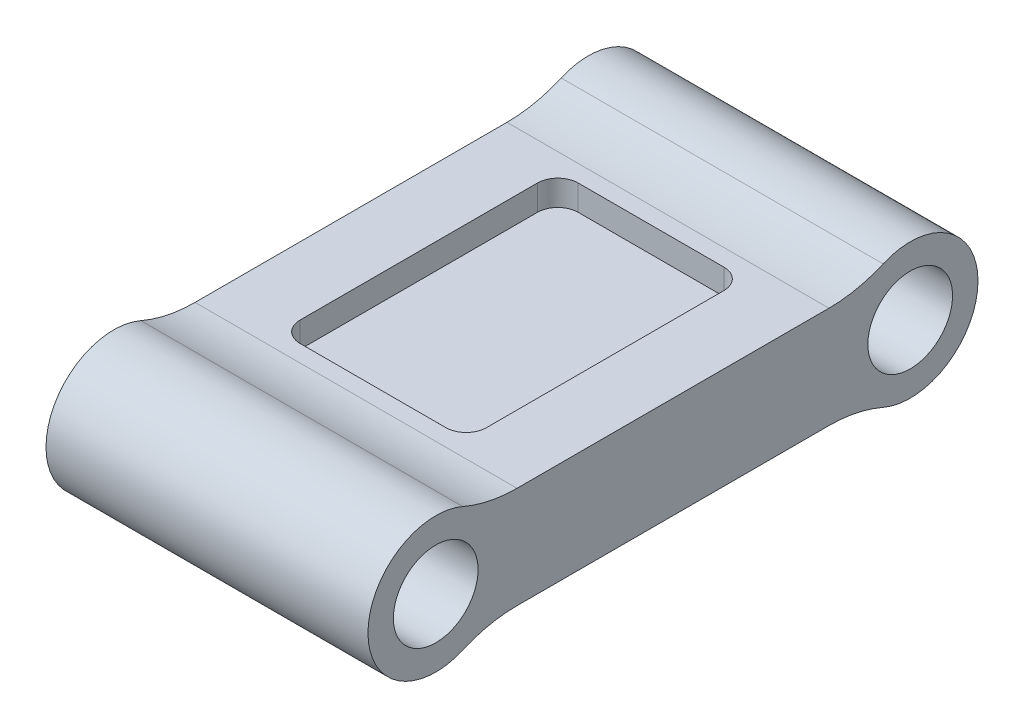
from build123d import *

# Parameters (mm, degrees)
SKETCH1_R               = 15.875
BOSS_EXTRUDE1_DEPTH     = 127
FILLET1_R               = 50.8
SKETCH2_W               = 25.4
SKETCH2_H               = 241.689615924
CUT_EXTRUDE1_DEPTH      = 7.35
CUT_EXTRUDE1_DEPTH_BACK = 45.45
SKETCH3_W               = 69.85
SKETCH3_H               = 104.192939654
CUT_EXTRUDE2_DEPTH      = 9.525
FILLET2_R               = 7.62
FILLET2_OF_MIRROR1_R    = 7.62


with BuildPart() as part:
    # Sketch1 → Boss-Extrude1 (new body)
    with BuildSketch(Plane(origin=(0, 0, 0), x_dir=(0, 0, -1), z_dir=(1, 0, 0))):
        with BuildLine():
            ThreePointArc((16.800520825, 19.05), (-25.4, 0), (16.800520825, -19.05))
            Line((16.800520825, -19.05), (160.999479175, -19.05))
            ThreePointArc((160.999479175, -19.05), (203.2, 0), (160.999479175, 19.05))
            Line((160.999479175, 19.05), (16.800520825, 19.05))
        make_face()
        Circle(SKETCH1_R, mode=Mode.SUBTRACT)
        with Locations((177.8, 0)):
            Circle(SKETCH1_R, mode=Mode.SUBTRACT)
    extrude(amount=BOSS_EXTRUDE1_DEPTH)

    # Fillet1
    fillet1_edges = [part.edges().sort_by_distance(p)[0] for p in [
        (63.5, -19.05, -16.800520825),
        (63.5, 19.05, -16.800520825),
        (63.5, 19.05, -160.999479175),
        (63.5, -19.05, -160.999479175),
    ]]
    fillet(fillet1_edges, radius=FILLET1_R)

    # Sketch2 → Cut-Extrude1 (cut, two sides)
    with BuildSketch(Plane(origin=(0, 19.05, 0), x_dir=(1, 0, 0), z_dir=(0, 1, 0))) as cut_extrude1_sk:
        with Locations((133.35, 89.453065483)):
            Rectangle(SKETCH2_W, SKETCH2_H)
    extrude(amount=CUT_EXTRUDE1_DEPTH, mode=Mode.SUBTRACT)
    extrude(cut_extrude1_sk.sketch, amount=-CUT_EXTRUDE1_DEPTH_BACK, mode=Mode.SUBTRACT)

    # Sketch3 → Cut-Extrude2 (cut)
    with BuildSketch(Plane(origin=(0, 19.05, 0), x_dir=(1, 0, 0), z_dir=(0, 1, 0))):
        with Locations((60.325, 88.9)):
            Rectangle(SKETCH3_W, SKETCH3_H)
    cut_extrude2 = extrude(amount=-CUT_EXTRUDE2_DEPTH, mode=Mode.SUBTRACT)

    # Fillet2
    fillet2_edges = [part.edges().sort_by_distance(p)[0] for p in [
        (25.4, 14.2875, -36.803530173),
        (25.4, 14.2875, -140.996469827),
        (95.25, 14.2875, -140.996469827),
        (95.25, 14.2875, -36.803530173),
    ]]
    fillet(fillet2_edges, radius=FILLET2_R)

    # Mirror1: Cut-Extrude2 across plane
    add(cut_extrude2.mirror(Plane.ZX), mode=Mode.SUBTRACT)

    # Fillet2 of Mirror1
    fillet2_of_mirror1_edges = [part.edges().sort_by_distance(p)[0] for p in [
        (25.4, -14.2875, -36.803530173),
        (25.4, -14.2875, -140.996469827),
        (95.25, -14.2875, -140.996469827),
        (95.25, -14.2875, -36.803530173),
    ]]
    fillet(fillet2_of_mirror1_edges, radius=FILLET2_OF_MIRROR1_R)


solid = part.part
